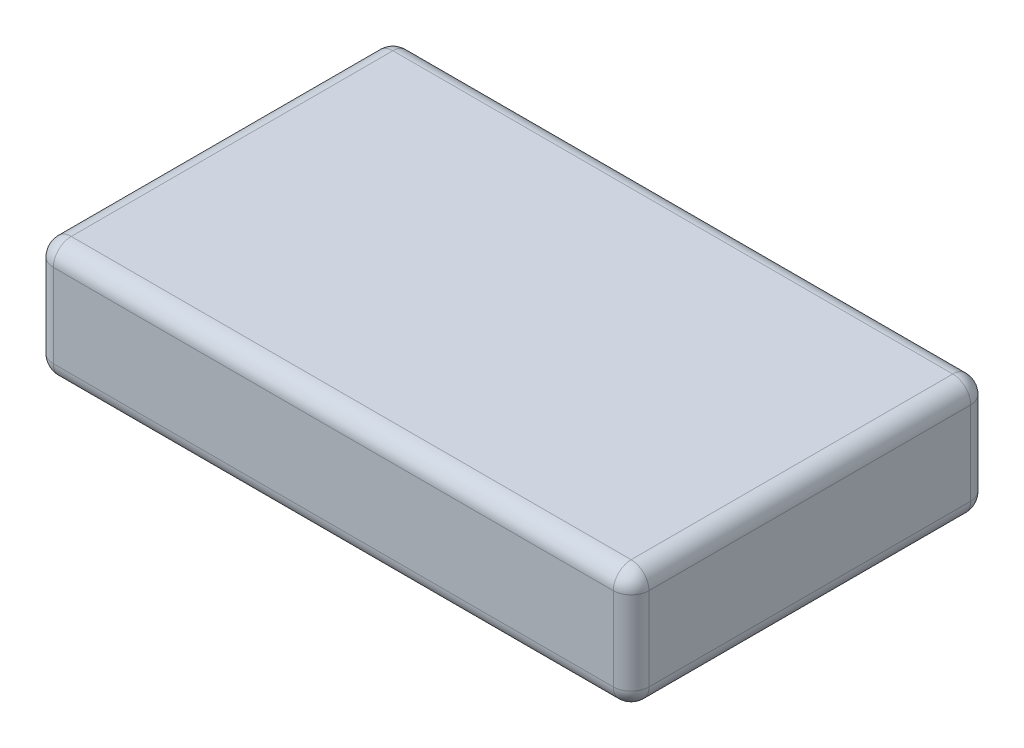
from build123d import *

# Parameters (mm, degrees)
SKETCH_1_W      = 100
SKETCH_1_H      = 60
EXTRUDE_1_DEPTH = 20
FILLET_1_R      = 3


with BuildPart() as part:
    # 草图1 → 凸台-拉伸1 (new body)
    with BuildSketch(Plane(origin=(0, 0, 0), x_dir=(1, 0, 0), z_dir=(0, 1, 0))):
        Rectangle(SKETCH_1_W, SKETCH_1_H)
    extrude(amount=EXTRUDE_1_DEPTH)

    # 圆角1
    fillet_1_edges = [part.edges().sort_by_distance(p)[0] for p in [
        (-50, 20, 0),
        (0, 20, 30),
        (50, 20, 0),
        (0, 0, 30),
        (-50, 0, 0),
        (0, 0, -30),
        (50, 0, 0),
        (50, 10, 30),
        (-50, 10, 30),
        (-50, 10, -30),
        (50, 10, -30),
        (0, 20, -30),
    ]]
    fillet(fillet_1_edges, radius=FILLET_1_R)


solid = part.part
